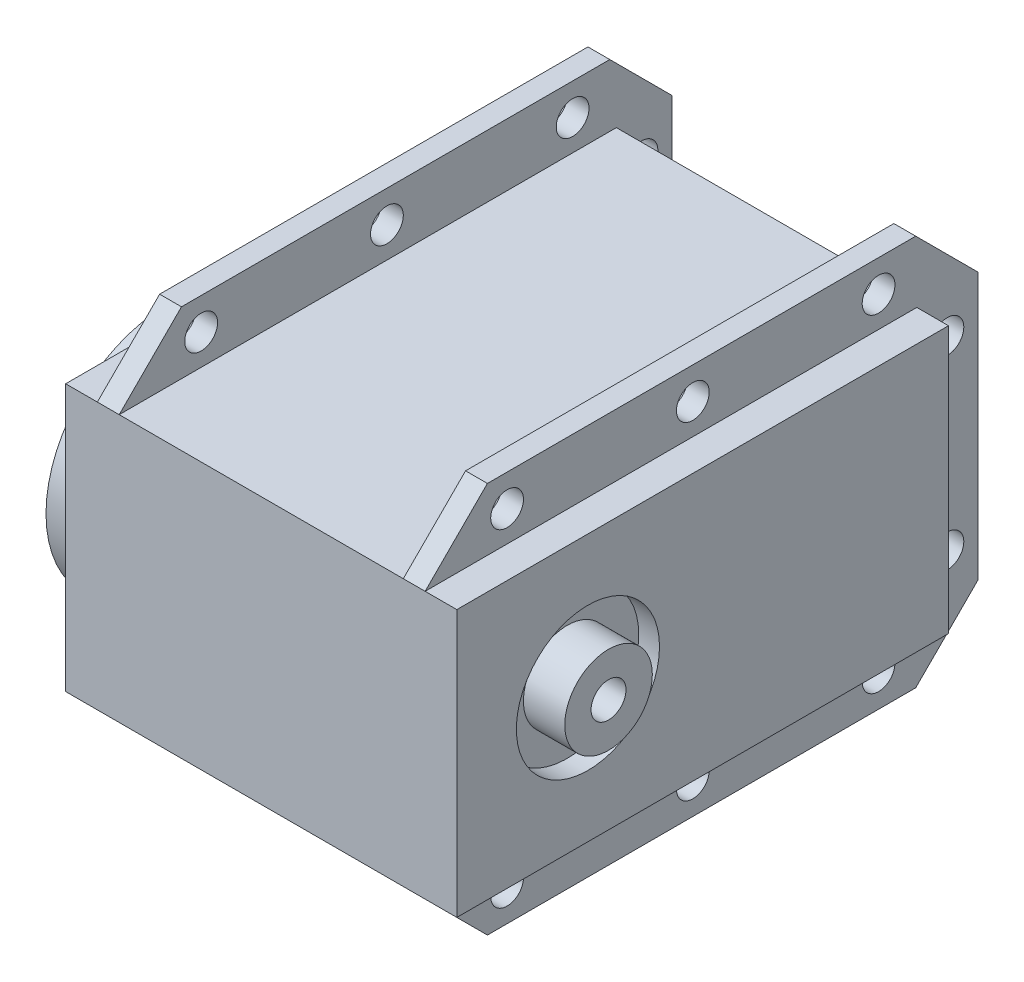
from build123d import *

# Parameters (mm, degrees)
SKETCH1_W                    = 45.5
SKETCH1_H                    = 30.1
BOSS_EXTRUDE1_DEPTH          = 30
SKETCH2_W                    = 28
SKETCH2_H                    = 5.7
CUT_EXTRUDE1_DEPTH           = 216.776564
SKETCH3_W                    = 2
SKETCH3_H                    = 30.1
BOSS_EXTRUDE2_DEPTH          = 5.1
SKETCH4_W                    = 2
SKETCH4_H                    = 50.6
BOSS_EXTRUDE3_DEPTH          = 5.7
SKETCH5_W                    = 2
SKETCH5_H                    = 45.5
BOSS_EXTRUDE4_DEPTH          = 5.7
SKETCH6_W                    = 2
SKETCH6_H                    = 30.1
BOSS_EXTRUDE5_DEPTH          = 5.1
SKETCH7_W                    = 2
SKETCH7_H                    = 50.6
BOSS_EXTRUDE6_DEPTH          = 5.7
SKETCH8_W                    = 45
SKETCH8_H                    = 24.4
BOSS_EXTRUDE7_DEPTH          = 2.9
SKETCH9_W                    = 45
SKETCH9_H                    = 24.4
BOSS_EXTRUDE8_DEPTH          = 2.9
M12_CLEARANCE_HOLE1_D        = 13.1
M12_CLEARANCE_HOLE1_DEPTH    = 1.9
SKETCH12_W                   = 3.784934
SKETCH12_H                   = 4.007989
F_3_0_3_DIAMETER_HOLE1_D     = 3
F_3_0_3_DIAMETER_HOLE1_DEPTH = 2
F_3_0_3_DIAMETER_HOLE2_D     = 3
F_3_0_3_DIAMETER_HOLE2_DEPTH = 38.7
F_3_0_3_DIAMETER_HOLE3_D     = 3
F_3_0_3_DIAMETER_HOLE3_DEPTH = 6.784935
F_2_0_2_DIAMETER_HOLE1_D     = 2
F_2_0_2_DIAMETER_HOLE1_DEPTH = 2
CHAMFER1_SIZE                = 5.7
SKETCH24_R                   = 1.6
CUT_EXTRUDE2_DEPTH           = 10


with BuildPart() as part:
    # Sketch1 → Boss-Extrude1 (new body)
    with BuildSketch(Plane(origin=(181.513958, 0, 0), x_dir=(0, 0, -1), z_dir=(1, 0, 0))):
        with Locations((-630.965155, 92.383509)):
            Rectangle(SKETCH1_W, SKETCH1_H)
    extrude(amount=-BOSS_EXTRUDE1_DEPTH)

    # Sketch2 → Cut-Extrude1 (cut, through all)
    with BuildSketch(Plane(origin=(0, 0, 608.215155), x_dir=(-1, 0, 0), z_dir=(0, 0, -1))):
        with Locations((-165.513958, 104.583509)):
            Rectangle(SKETCH2_W, SKETCH2_H)
    extrude(amount=-CUT_EXTRUDE1_DEPTH, mode=Mode.SUBTRACT)

    # Sketch3 → Boss-Extrude2 (add)
    with BuildSketch(Plane(origin=(0, 0, 608.215155), x_dir=(-1, 0, 0), z_dir=(0, 0, -1))):
        with Locations((-180.513958, 92.383509)):
            Rectangle(SKETCH3_W, SKETCH3_H)
    extrude(amount=BOSS_EXTRUDE2_DEPTH)

    # Sketch4 → Boss-Extrude3 (add)
    with BuildSketch(Plane.XZ.offset(-77.333509)):
        with Locations((180.513958, 628.415155)):
            Rectangle(SKETCH4_W, SKETCH4_H)
    extrude(amount=BOSS_EXTRUDE3_DEPTH)

    # Sketch5 → Boss-Extrude4 (add)
    with BuildSketch(Plane.XZ.offset(-77.333509)):
        with Locations((152.513958, 630.965155)):
            Rectangle(SKETCH5_W, SKETCH5_H)
    extrude(amount=BOSS_EXTRUDE4_DEPTH)

    # Sketch6 → Boss-Extrude5 (add)
    with BuildSketch(Plane(origin=(0, 0, 608.215155), x_dir=(-1, 0, 0), z_dir=(0, 0, -1))):
        with Locations((-152.513958, 86.683509)):
            Rectangle(SKETCH6_W, SKETCH6_H)
    extrude(amount=BOSS_EXTRUDE5_DEPTH)

    # Sketch7 → Boss-Extrude6 (add)
    with BuildSketch(Plane(origin=(0, 101.733509, 0), x_dir=(-1, 0, 0), z_dir=(0, 1, 0))):
        with Locations((-152.513958, 628.415155)):
            Rectangle(SKETCH7_W, SKETCH7_H)
    extrude(amount=BOSS_EXTRUDE6_DEPTH)

    # Sketch8 → Boss-Extrude7 (add)
    with BuildSketch(Plane.ZY.offset(-151.513958)):
        with Locations((631.215155, 89.533509)):
            Rectangle(SKETCH8_W, SKETCH8_H)
    extrude(amount=BOSS_EXTRUDE7_DEPTH)

    # Sketch9 → Boss-Extrude8 (add)
    with BuildSketch(Plane(origin=(181.513958, 0, 0), x_dir=(0, 0, -1), z_dir=(1, 0, 0))):
        with Locations((-631.215155, 89.533509)):
            Rectangle(SKETCH9_W, SKETCH9_H)
    extrude(amount=BOSS_EXTRUDE8_DEPTH)

    # M12 Clearance Hole1
    with Locations(Plane(origin=(184.413958, 0, 0), x_dir=(0, 0, -1), z_dir=(1, 0, 0))):
        with Locations((-641.715155, 89.533509)):
            Hole(M12_CLEARANCE_HOLE1_D / 2, depth=M12_CLEARANCE_HOLE1_DEPTH)

    # Sketch12 → Revolve1 (revolve)
    with BuildSketch(Plane.XY.offset(641.715155), mode=Mode.PRIVATE) as revolve1_sk:
        with Locations((184.406425, 91.529515)):
            Rectangle(SKETCH12_W, SKETCH12_H)
    revolve(revolve1_sk.sketch.rotate(Axis((182.513958, 89.52552, 641.715155), (1, 0, 0)), 270), axis=Axis((182.513958, 89.52552, 641.715155), (1, 0, 0)))

    # Sketch13 → Revolve2 (revolve)
    with BuildSketch(Plane.XY.offset(641.715155), mode=Mode.PRIVATE) as revolve2_sk:
        Polygon((142.813958, 93.533509), (142.813958, 89.533509), (148.613958, 89.533509), (148.613958, 93.533509), (147.813958, 93.533509), (147.813958, 100.533509), (145.813958, 100.533509), (145.813958, 93.533509), align=None)
    revolve(revolve2_sk.sketch.rotate(Axis((142.813958, 89.533509, 641.715155), (1, 0, 0)), 270), axis=Axis((142.813958, 89.533509, 641.715155), (1, 0, 0)))

    # Ø3.0 (3) Diameter Hole1
    with Locations(Plane.ZY.offset(-151.513958)):
        with Locations((612.215155, 104.533509), (612.215155, 74.533509), (605.915155, 81.033509), (605.915155, 98.033509), (646.215155, 104.533509), (646.215155, 74.533509), (629.215155, 104.533509), (629.215155, 74.533509)):
            Hole(F_3_0_3_DIAMETER_HOLE1_D / 2, depth=F_3_0_3_DIAMETER_HOLE1_DEPTH)

    # Ø3.0 (3) Diameter Hole2
    with Locations(Plane(origin=(181.513958, 0, 0), x_dir=(0, 0, -1), z_dir=(1, 0, 0))):
        with Locations((-605.915155, 81.033509)):
            Hole(F_3_0_3_DIAMETER_HOLE2_D / 2, depth=F_3_0_3_DIAMETER_HOLE2_DEPTH)

    # Ø3.0 (3) Diameter Hole3
    with Locations(Plane.ZY.offset(-179.513958)):
        with Locations((612.215155, 104.533509), (612.215155, 74.533509), (605.915155, 98.033509), (629.215155, 74.533509), (629.215155, 104.533509), (646.215155, 74.533509), (646.215155, 104.533509)):
            Hole(F_3_0_3_DIAMETER_HOLE3_D / 2, depth=F_3_0_3_DIAMETER_HOLE3_DEPTH)

    # Ø2.0 (2) Diameter Hole1
    with Locations(Plane.ZY.offset(-145.813958)):
        with Locations((641.715155, 98.033509), (641.715155, 81.033509), (633.215155, 89.533509), (650.215155, 89.533509)):
            Hole(F_2_0_2_DIAMETER_HOLE1_D / 2, depth=F_2_0_2_DIAMETER_HOLE1_DEPTH)

    # Sketch22 → M2x0.4 Tapped Hole1 (revolve, cut)
    with BuildSketch(Plane(origin=(142.813958, 89.533509, 641.715155), x_dir=(0, 0, 1), z_dir=(0, 1, 0))):
        Polygon((0, 0), (0, 1.8), (2.5, 1.8), (2.5, 1), (1.25, 1), (1.25, 0), align=None)
    revolve(axis=Axis((136.463958, 89.533509, 641.715155), (1, 0, 0)), mode=Mode.SUBTRACT)

    # Chamfer1
    chamfer1_edges = [part.edges().sort_by_distance(p)[0] for p in [
        (152.513958, 107.433509, 603.115155),
        (152.513958, 71.633509, 653.715155),
        (152.513958, 71.633509, 603.115155),
        (180.513958, 71.633509, 603.115155),
        (152.513958, 107.433509, 653.715155),
        (180.513958, 107.433509, 653.715155),
        (180.513958, 107.433509, 603.115155),
        (180.513958, 71.633509, 653.715155),
    ]]
    chamfer(chamfer1_edges, length=CHAMFER1_SIZE)

    # Sketch24 → Cut-Extrude2 (cut)
    with BuildSketch(Plane(origin=(186.298892, 0, 0), x_dir=(0, 0, -1), z_dir=(1, 0, 0))):
        with Locations((-641.715155, 89.52552)):
            Circle(SKETCH24_R)
    extrude(amount=-CUT_EXTRUDE2_DEPTH, mode=Mode.SUBTRACT)


solid = part.part
